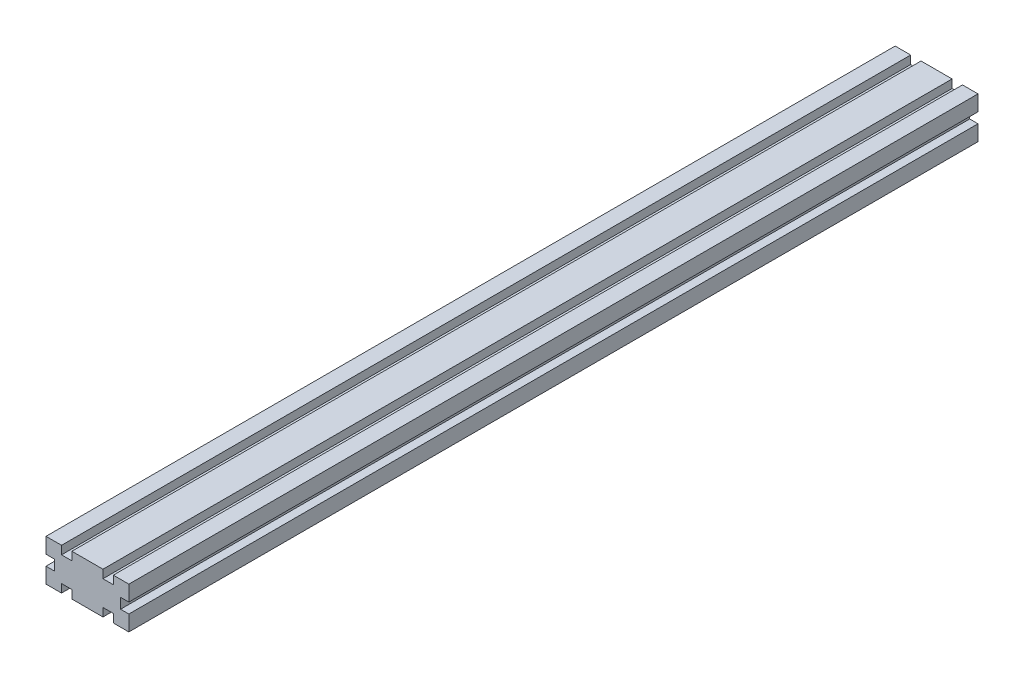
from build123d import *

# Parameters (mm, degrees)
ESQUISSE1_W        = 3.5
ESQUISSE1_H        = 5
ESQUISSE1_W_2      = 5
ESQUISSE1_H_2      = 3.5
ESQUISSE1_W_3      = 4
BOSS_EXTRU_1_DEPTH = 410


with BuildPart() as part:
    # Esquisse1 → Boss.-Extru.1 (new body)
    with BuildSketch(Plane.XY):
        Polygon((7.5, 16), (7.5, 20), (0, 20), (4, 16), align=None)
        Polygon((4, 16), (0, 20), (0, 12.5), (4, 12.5), align=None)
        Polygon((4, 7.5), (0, 7.5), (0, 0), (4, 4), align=None)
        Polygon((0, 0), (7.5, 0), (7.5, 4), (4, 4), align=None)
        Polygon((4, 4), (7.5, 7.5), (4, 7.5), align=None)
        Polygon((7.5, 4), (7.5, 7.5), (4, 4), align=None)
        Polygon((4, 12.5), (7.5, 12.5), (4, 16), align=None)
        Polygon((7.5, 12.5), (7.5, 16), (4, 16), align=None)
        with Locations((5.75, 10)):
            Rectangle(ESQUISSE1_W, ESQUISSE1_H)
        Polygon((7.5, 7.5), (10, 10), (7.5, 12.5), align=None)
        Polygon((10, 10), (12.5, 12.5), (7.5, 12.5), align=None)
        Polygon((12.5, 7.5), (12.5, 12.5), (10, 10), align=None)
        Polygon((12.5, 7.5), (10, 10), (7.5, 7.5), align=None)
        Polygon((16, 4), (12.5, 7.5), (12.5, 4), align=None)
        Polygon((16, 4), (16, 7.5), (12.5, 7.5), align=None)
        Polygon((20, 0), (20, 7.5), (16, 7.5), (16, 4), align=None)
        with Locations((10, 14.25)):
            Rectangle(ESQUISSE1_W_2, ESQUISSE1_H_2)
        with Locations((14.25, 10)):
            Rectangle(ESQUISSE1_W, ESQUISSE1_H)
        Polygon((12.5, 12.5), (16, 16), (12.5, 16), align=None)
        Polygon((16, 16), (20, 20), (12.5, 20), (12.5, 16), align=None)
        Polygon((16, 12.5), (16, 16), (12.5, 12.5), align=None)
        Polygon((20, 12.5), (20, 20), (16, 16), (16, 12.5), align=None)
        Polygon((12.5, 0), (20, 0), (16, 4), (12.5, 4), align=None)
        with Locations((10, 5.75)):
            Rectangle(ESQUISSE1_W_2, ESQUISSE1_H_2)
        with Locations((18, 10)):
            Rectangle(ESQUISSE1_W_3, ESQUISSE1_H)
        with Locations((22, 10)):
            Rectangle(ESQUISSE1_W_3, ESQUISSE1_H)
        Polygon((24, 16), (20, 20), (20, 12.5), (24, 12.5), align=None)
        Polygon((27.5, 20), (20, 20), (24, 16), (27.5, 16), align=None)
        Polygon((27.5, 12.5), (24, 16), (24, 12.5), align=None)
        Polygon((27.5, 16), (24, 16), (27.5, 12.5), align=None)
        with Locations((25.75, 10)):
            Rectangle(ESQUISSE1_W, ESQUISSE1_H)
        Polygon((27.5, 7.5), (24, 7.5), (24, 4), align=None)
        Polygon((24, 7.5), (20, 7.5), (20, 0), (24, 4), align=None)
        Polygon((24, 4), (20, 0), (27.5, 0), (27.5, 4), align=None)
        Polygon((27.5, 4), (27.5, 7.5), (24, 4), align=None)
        with Locations((30, 5.75)):
            Rectangle(ESQUISSE1_W_2, ESQUISSE1_H_2)
        Polygon((36, 4), (32.5, 7.5), (32.5, 4), align=None)
        Polygon((36, 7.5), (32.5, 7.5), (36, 4), align=None)
        Polygon((40, 0), (40, 7.5), (36, 7.5), (36, 4), align=None)
        Polygon((32.5, 4), (32.5, 0), (40, 0), (36, 4), align=None)
        with Locations((34.25, 10)):
            Rectangle(ESQUISSE1_W, ESQUISSE1_H)
        Polygon((32.5, 12.5), (30, 10), (32.5, 7.5), align=None)
        Polygon((32.5, 7.5), (30, 10), (27.5, 7.5), align=None)
        Polygon((30, 10), (27.5, 12.5), (27.5, 7.5), align=None)
        Polygon((32.5, 12.5), (27.5, 12.5), (30, 10), align=None)
        Polygon((36, 16), (32.5, 12.5), (36, 12.5), align=None)
        Polygon((36, 16), (32.5, 16), (32.5, 12.5), align=None)
        Polygon((40, 20), (32.5, 20), (32.5, 16), (36, 16), align=None)
        Polygon((40, 12.5), (40, 20), (36, 16), (36, 12.5), align=None)
        with Locations((30, 14.25)):
            Rectangle(ESQUISSE1_W_2, ESQUISSE1_H_2)
    extrude(amount=BOSS_EXTRU_1_DEPTH)


solid = part.part
